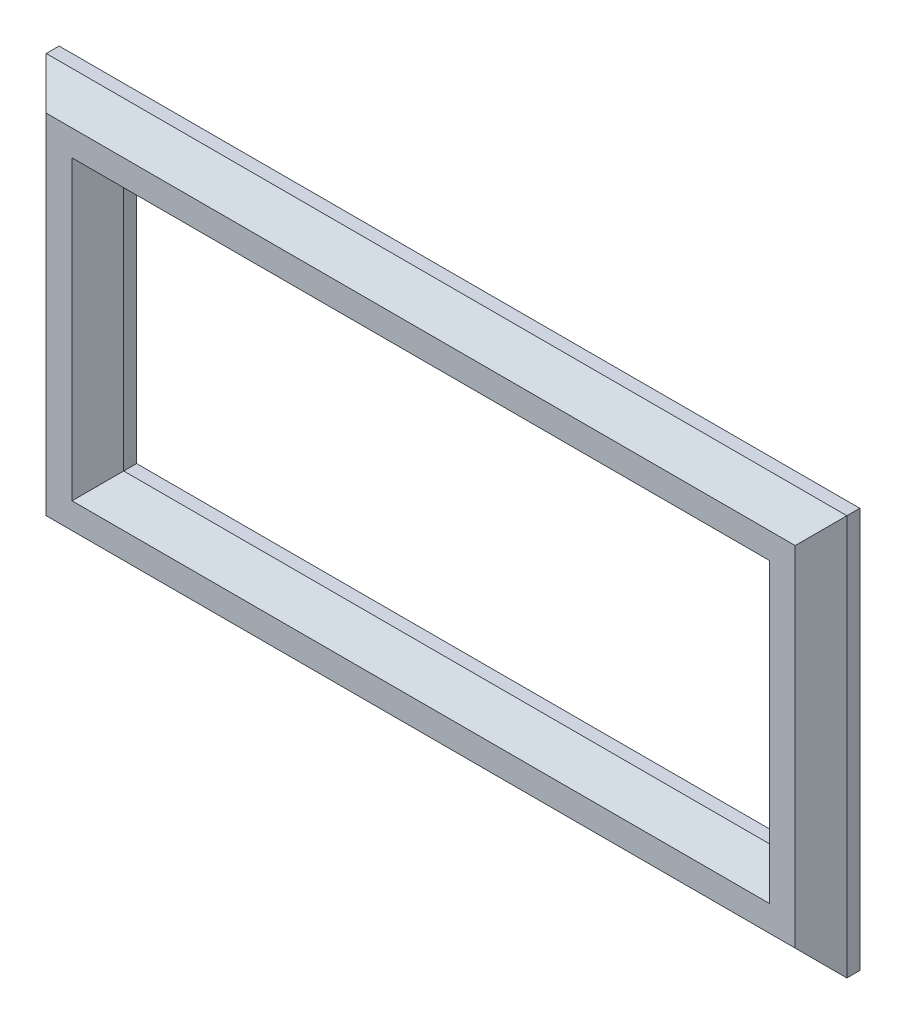
from build123d import *

# Parameters (mm, degrees)
ESQUISSE1_W        = 62
ESQUISSE1_H        = 31
ESQUISSE1_W_2      = 50
ESQUISSE1_H_2      = 19
BOSS_EXTRU_1_DEPTH = 3
CHANFREIN1_SIZE    = 2


with BuildPart() as part:
    # Esquisse1 → Boss.-Extru.1 (new body)
    with BuildSketch(Plane.XY):
        with Locations((-25, 9.5)):
            Rectangle(ESQUISSE1_W, ESQUISSE1_H)
        with Locations((-25, 9.5)):
            Rectangle(ESQUISSE1_W_2, ESQUISSE1_H_2, mode=Mode.SUBTRACT)
    extrude(amount=BOSS_EXTRU_1_DEPTH)

    # Chanfrein1
    chanfrein1_edges = [part.edges().sort_by_distance(p)[0] for p in [
        (-56, 9.5, 3),
        (-25, -6, 3),
        (0, 9.5, 3),
        (-25, 19, 3),
        (-50, 9.5, 3),
        (-25, 0, 3),
        (6, 9.5, 3),
        (-25, 25, 3),
    ]]
    chamfer(chanfrein1_edges, length=CHANFREIN1_SIZE)


solid = part.part
